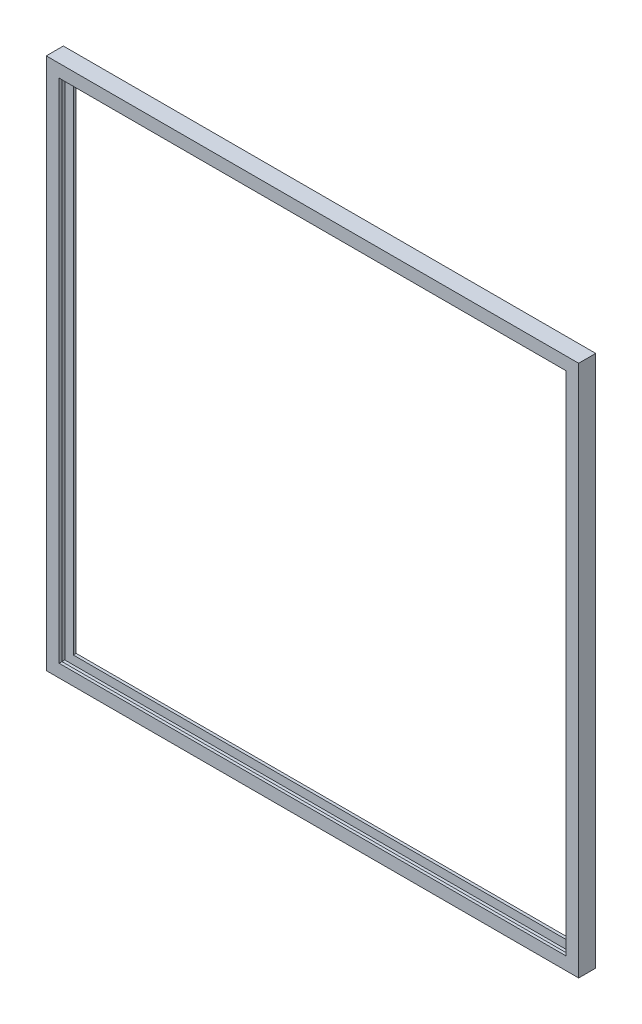
from build123d import *


with BuildPart() as part:
    # Sweep1: sweep along a path in Sketch2
    with BuildLine(Plane.XY) as sweep1_path:
        Line((-296.8625, 593.725), (296.8625, 593.725))
        Line((296.8625, 593.725), (296.8625, 0))
        Line((296.8625, 0), (-296.8625, 0))
        Line((-296.8625, 0), (-296.8625, 593.725))
    # Sketch1 → Sweep1 (sweep)
    with BuildSketch(Plane(origin=(0, 0, 0), x_dir=(0, 0, -1), z_dir=(1, 0, 0))):
        Polygon((-9.525, 14.2875), (-9.525, 0), (9.525, 0), (9.525, 14.2875), (6.35, 14.2875), (6.35, 4.7625), (-6.35, 4.7625), (-6.35, 14.2875), align=None)
    sweep(path=sweep1_path.line, transition=Transition.RIGHT)


solid = part.part
